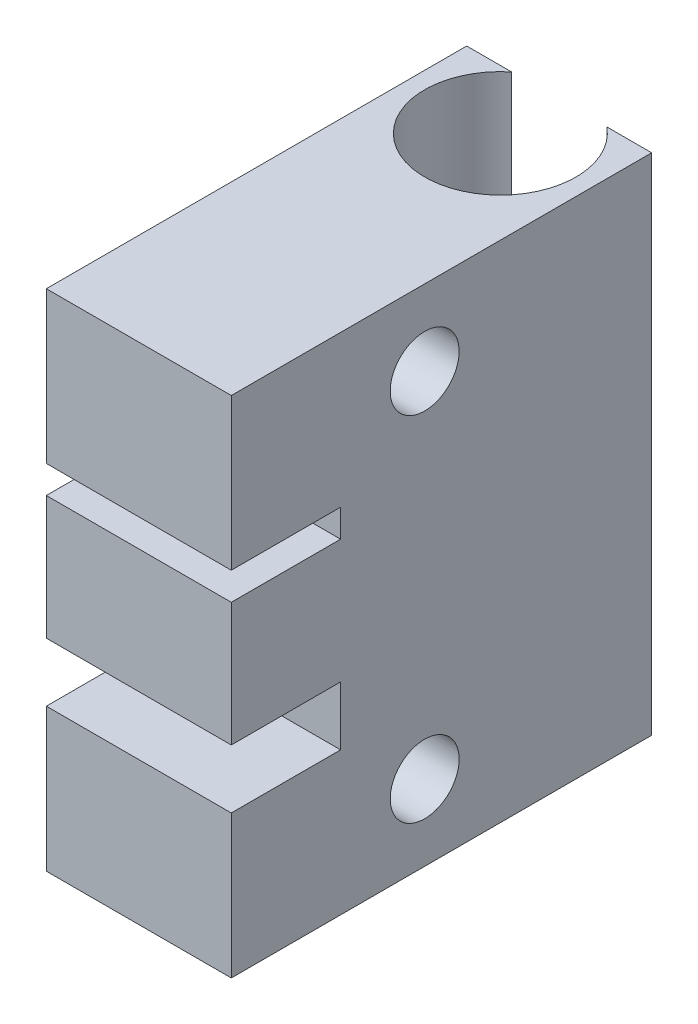
from build123d import *

# Parameters (mm, degrees)
SKETCH1_W           = 22
SKETCH1_H           = 50
BOSS_EXTRUDE1_DEPTH = 60
SKETCH2_R           = 4.1
CUT_EXTRUDE1_DEPTH  = 23
SKETCH4_R           = 9
CUT_EXTRUDE2_DEPTH  = 61
SKETCH5_W           = 22
SKETCH5_H           = 3.3
SKETCH5_H_2         = 7
CUT_EXTRUDE3_DEPTH  = 13


with BuildPart() as part:
    # Sketch1 → Boss-Extrude1 (new body)
    with BuildSketch(Plane(origin=(0, 0, 0), x_dir=(1, 0, 0), z_dir=(0, 1, 0))):
        Rectangle(SKETCH1_W, SKETCH1_H)
    extrude(amount=BOSS_EXTRUDE1_DEPTH)

    # Sketch2 → Cut-Extrude1 (cut, through all)
    with BuildSketch(Plane(origin=(11, 0, 0), x_dir=(0, 0, -1), z_dir=(1, 0, 0))):
        with Locations((-2, 51)):
            Circle(SKETCH2_R)
        with Locations((-2, 9)):
            Circle(SKETCH2_R)
    extrude(amount=-CUT_EXTRUDE1_DEPTH, mode=Mode.SUBTRACT)

    # Sketch4 → Cut-Extrude2 (cut, through all)
    with BuildSketch(Plane(origin=(0, 60, 0), x_dir=(1, 0, 0), z_dir=(0, 1, 0))):
        with Locations((0, 18)):
            Circle(SKETCH4_R)
    extrude(amount=-CUT_EXTRUDE2_DEPTH, mode=Mode.SUBTRACT)

    # Sketch5 → Cut-Extrude3 (cut)
    with BuildSketch(Plane.XY.offset(25)):
        with Locations((0, 40.35)):
            Rectangle(SKETCH5_W, SKETCH5_H)
        with Locations((0, 20.5)):
            Rectangle(SKETCH5_W, SKETCH5_H_2)
    extrude(amount=-CUT_EXTRUDE3_DEPTH, mode=Mode.SUBTRACT)


solid = part.part
